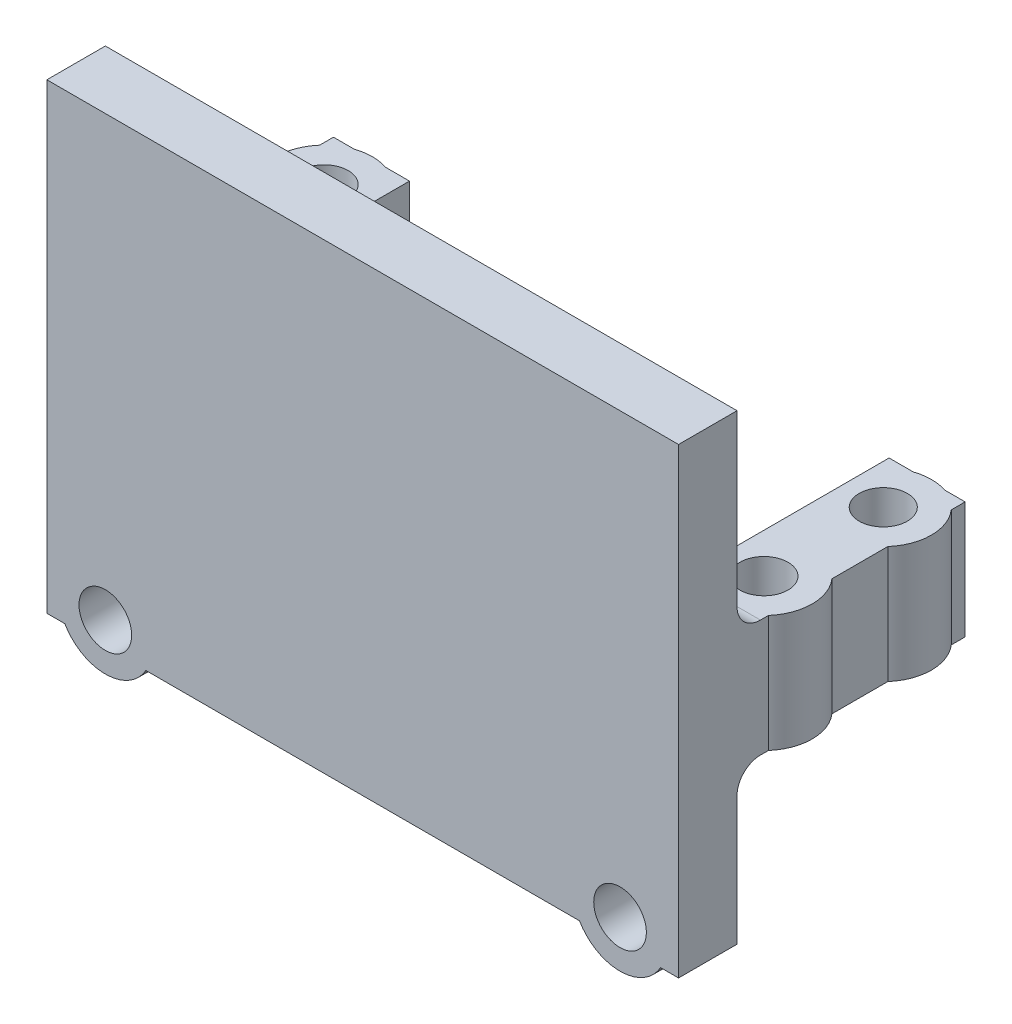
from build123d import *

# Parameters (mm, degrees)
SKETCH1_W           = 54
SKETCH1_H           = 26.5
BOSS_EXTRUDE1_DEPTH = 5
SKETCH2_W           = 6.5
SKETCH2_H           = 10
BOSS_EXTRUDE2_DEPTH = 19.5
SKETCH3_R           = 2.06
CUT_EXTRUDE1_DEPTH  = 19
SKETCH4_R           = 2.06
BOSS_EXTRUDE3_DEPTH = 10
FILLET1_R           = 1
FILLET2_R           = 2
SKETCH5_W           = 54
SKETCH5_H           = 5
BOSS_EXTRUDE4_DEPTH = 13
SKETCH6_R           = 2.25
CUT_EXTRUDE2_DEPTH  = 15
FILLET3_R           = 2
SKETCH7_R           = 4
SKETCH7_R_2         = 2.25
BOSS_EXTRUDE5_DEPTH = 5


with BuildPart() as part:
    # Sketch1 → Boss-Extrude1 (new body)
    with BuildSketch(Plane.XY):
        Rectangle(SKETCH1_W, SKETCH1_H)
    extrude(amount=BOSS_EXTRUDE1_DEPTH)

    # Sketch2 → Boss-Extrude2 (add)
    with BuildSketch(Plane(origin=(0, 0, 0), x_dir=(-1, 0, 0), z_dir=(0, 0, -1))):
        with Locations((-23.75, -8.25)):
            Rectangle(SKETCH2_W, SKETCH2_H)
        with Locations((23.75, -8.25)):
            Rectangle(SKETCH2_W, SKETCH2_H)
    extrude(amount=BOSS_EXTRUDE2_DEPTH)

    # Sketch3 → Cut-Extrude1 (cut)
    with BuildSketch(Plane.XZ.offset(13.25)):
        with Locations((23.9, -15.6)):
            Circle(SKETCH3_R)
        with Locations((-23.9, -5.4)):
            Circle(SKETCH3_R)
        with Locations((23.9, -5.4)):
            Circle(SKETCH3_R)
        with Locations((-23.9, -15.6)):
            Circle(SKETCH3_R)
    extrude(amount=-CUT_EXTRUDE1_DEPTH, mode=Mode.SUBTRACT)

    # Sketch4 → Boss-Extrude3 (add)
    with BuildSketch(Plane.XZ.offset(13.25)):
        with BuildLine():
            Line((20.5, -17.926886332), (20.5, -13.273113668))
            ThreePointArc((20.5, -13.273113668), (28.02, -15.6), (20.5, -17.926886332))
        make_face()
        with Locations((23.9, -15.6)):
            Circle(SKETCH4_R, mode=Mode.SUBTRACT)
        with BuildLine():
            Line((20.5, -7.726886332), (20.5, -3.073113668))
            ThreePointArc((20.5, -3.073113668), (28.02, -5.4), (20.5, -7.726886332))
        make_face()
        with Locations((23.9, -5.4)):
            Circle(SKETCH4_R, mode=Mode.SUBTRACT)
        with BuildLine():
            Line((-20.5, -7.726886332), (-20.5, -3.073113668))
            ThreePointArc((-20.5, -3.073113668), (-28.02, -5.4), (-20.5, -7.726886332))
        make_face()
        with Locations((-23.9, -5.4)):
            Circle(SKETCH4_R, mode=Mode.SUBTRACT)
        with BuildLine():
            Line((-20.5, -17.926886332), (-20.5, -13.273113668))
            ThreePointArc((-20.5, -13.273113668), (-28.02, -15.6), (-20.5, -17.926886332))
        make_face()
        with Locations((-23.9, -15.6)):
            Circle(SKETCH4_R, mode=Mode.SUBTRACT)
    extrude(amount=-BOSS_EXTRUDE3_DEPTH)

    # Fillet1
    fillet1_edges = [part.edges().sort_by_distance(p)[0] for p in [
        (20.5, -8.25, 0),
        (-20.5, -8.25, 0),
    ]]
    fillet(fillet1_edges, radius=FILLET1_R)

    # Fillet2
    fillet2_edges = [part.edges().sort_by_distance(p)[0] for p in [
        (23.75, -3.25, 0),
        (-23.75, -3.25, 0),
    ]]
    fillet(fillet2_edges, radius=FILLET2_R)

    # Sketch5 → Boss-Extrude4 (add)
    with BuildSketch(Plane.XZ.offset(13.25)):
        with Locations((0, 2.5)):
            Rectangle(SKETCH5_W, SKETCH5_H)
    extrude(amount=BOSS_EXTRUDE4_DEPTH)

    # Sketch6 → Cut-Extrude2 (cut)
    with BuildSketch(Plane(origin=(0, 0, 0), x_dir=(-1, 0, 0), z_dir=(0, 0, -1))):
        with Locations((22, -24.25)):
            Circle(SKETCH6_R)
        with Locations((-22, -24.25)):
            Circle(SKETCH6_R)
    extrude(amount=-CUT_EXTRUDE2_DEPTH, mode=Mode.SUBTRACT)

    # Fillet3
    fillet3_edges = [part.edges().sort_by_distance(p)[0] for p in [
        (23.25, -13.25, 0),
        (-23.25, -13.25, 0),
    ]]
    fillet(fillet3_edges, radius=FILLET3_R)

    # Sketch7 → Boss-Extrude5 (add)
    with BuildSketch(Plane(origin=(0, 0, 0), x_dir=(-1, 0, 0), z_dir=(0, 0, -1))):
        with Locations((22, -24.25)):
            Circle(SKETCH7_R)
        with Locations((22, -24.25)):
            Circle(SKETCH7_R_2, mode=Mode.SUBTRACT)
        with Locations((-22, -24.25)):
            Circle(SKETCH7_R)
        with Locations((-22, -24.25)):
            Circle(SKETCH7_R_2, mode=Mode.SUBTRACT)
    extrude(amount=-BOSS_EXTRUDE5_DEPTH)


solid = part.part
